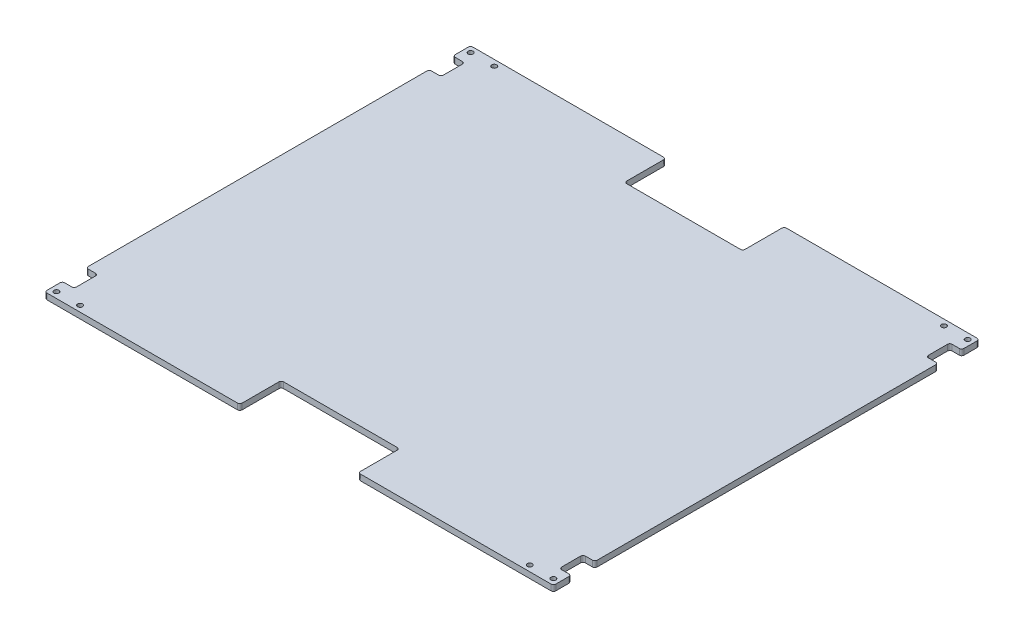
from build123d import *

# Parameters (mm, degrees)
SKETCH1_R           = 2.667
BOSS_EXTRUDE1_DEPTH = 6.35


with BuildPart() as part:
    # Sketch1 → Boss-Extrude1 (new body)
    with BuildSketch(Plane(origin=(0, 0, 0), x_dir=(1, 0, 0), z_dir=(0, 1, 0))):
        with BuildLine():
            Line((-273.05, 226.06), (-273.05, 212.09))
            ThreePointArc((-273.05, 212.09), (-272.306051224, 210.293948776), (-270.51, 209.55))
            Line((-270.51, 209.55), (-262.89, 209.55))
            ThreePointArc((-262.89, 209.55), (-261.093948776, 208.806051224), (-260.35, 207.01))
            Line((-260.35, 207.01), (-260.35, 186.69))
            ThreePointArc((-260.35, 186.69), (-261.093948776, 184.893948776), (-262.89, 184.15))
            Line((-262.89, 184.15), (-270.51, 184.15))
            ThreePointArc((-270.51, 184.15), (-272.306051224, 183.406051224), (-273.05, 181.61))
            Line((-273.05, 181.61), (-273.05, -181.61))
            ThreePointArc((-273.05, -181.61), (-272.306051224, -183.406051224), (-270.51, -184.15))
            Line((-270.51, -184.15), (-262.89, -184.15))
            ThreePointArc((-262.89, -184.15), (-261.093948776, -184.893948776), (-260.35, -186.69))
            Line((-260.35, -186.69), (-260.35, -207.01))
            ThreePointArc((-260.35, -207.01), (-261.093948776, -208.806051224), (-262.89, -209.55))
            Line((-262.89, -209.55), (-270.51, -209.55))
            ThreePointArc((-270.51, -209.55), (-272.306051224, -210.293948776), (-273.05, -212.09))
            Line((-273.05, -212.09), (-273.05, -226.06))
            ThreePointArc((-273.05, -226.06), (-272.306051224, -227.856051224), (-270.51, -228.6))
            Line((-270.51, -228.6), (-66.04, -228.6))
            ThreePointArc((-66.04, -228.6), (-64.243948776, -227.856051224), (-63.5, -226.06))
            Line((-63.5, -226.06), (-63.5, -186.69))
            ThreePointArc((-63.5, -186.69), (-62.756051224, -184.893948776), (-60.96, -184.15))
            Line((-60.96, -184.15), (60.96, -184.15))
            ThreePointArc((60.96, -184.15), (62.756051224, -184.893948776), (63.5, -186.69))
            Line((63.5, -186.69), (63.5, -226.06))
            ThreePointArc((63.5, -226.06), (64.243948776, -227.856051224), (66.04, -228.6))
            Line((66.04, -228.6), (270.51, -228.6))
            ThreePointArc((270.51, -228.6), (272.306051224, -227.856051224), (273.05, -226.06))
            Line((273.05, -226.06), (273.05, -212.09))
            ThreePointArc((273.05, -212.09), (272.306051224, -210.293948776), (270.51, -209.55))
            Line((270.51, -209.55), (262.89, -209.55))
            ThreePointArc((262.89, -209.55), (261.093948776, -208.806051224), (260.35, -207.01))
            Line((260.35, -207.01), (260.35, -186.69))
            ThreePointArc((260.35, -186.69), (261.093948776, -184.893948776), (262.89, -184.15))
            Line((262.89, -184.15), (270.51, -184.15))
            ThreePointArc((270.51, -184.15), (272.306051224, -183.406051224), (273.05, -181.61))
            Line((273.05, -181.61), (273.05, 181.61))
            ThreePointArc((273.05, 181.61), (272.306051224, 183.406051224), (270.51, 184.15))
            Line((270.51, 184.15), (262.89, 184.15))
            ThreePointArc((262.89, 184.15), (261.093948776, 184.893948776), (260.35, 186.69))
            Line((260.35, 186.69), (260.35, 207.01))
            ThreePointArc((260.35, 207.01), (261.093948776, 208.806051224), (262.89, 209.55))
            Line((262.89, 209.55), (270.51, 209.55))
            ThreePointArc((270.51, 209.55), (272.306051224, 210.293948776), (273.05, 212.09))
            Line((273.05, 212.09), (273.05, 226.06))
            ThreePointArc((273.05, 226.06), (272.306051224, 227.856051224), (270.51, 228.6))
            Line((270.51, 228.6), (66.04, 228.6))
            ThreePointArc((66.04, 228.6), (64.243948776, 227.856051224), (63.5, 226.06))
            Line((63.5, 226.06), (63.5, 186.69))
            ThreePointArc((63.5, 186.69), (62.756051224, 184.893948776), (60.96, 184.15))
            Line((60.96, 184.15), (-60.96, 184.15))
            ThreePointArc((-60.96, 184.15), (-62.756051224, 184.893948776), (-63.5, 186.69))
            Line((-63.5, 186.69), (-63.5, 226.06))
            ThreePointArc((-63.5, 226.06), (-64.243948776, 227.856051224), (-66.04, 228.6))
            Line((-66.04, 228.6), (-270.51, 228.6))
            ThreePointArc((-270.51, 228.6), (-272.306051224, 227.856051224), (-273.05, 226.06))
        make_face()
        with Locations((-266.7, 222.25)):
            Circle(SKETCH1_R, mode=Mode.SUBTRACT)
        with Locations((266.7, 222.25)):
            Circle(SKETCH1_R, mode=Mode.SUBTRACT)
        with Locations((-241.3, 222.25)):
            Circle(SKETCH1_R, mode=Mode.SUBTRACT)
        with Locations((241.3, 222.25)):
            Circle(SKETCH1_R, mode=Mode.SUBTRACT)
        with Locations((-266.7, -222.25)):
            Circle(SKETCH1_R, mode=Mode.SUBTRACT)
        with Locations((266.7, -222.25)):
            Circle(SKETCH1_R, mode=Mode.SUBTRACT)
        with Locations((-241.3, -222.25)):
            Circle(SKETCH1_R, mode=Mode.SUBTRACT)
        with Locations((241.3, -222.25)):
            Circle(SKETCH1_R, mode=Mode.SUBTRACT)
    extrude(amount=BOSS_EXTRUDE1_DEPTH)


solid = part.part
